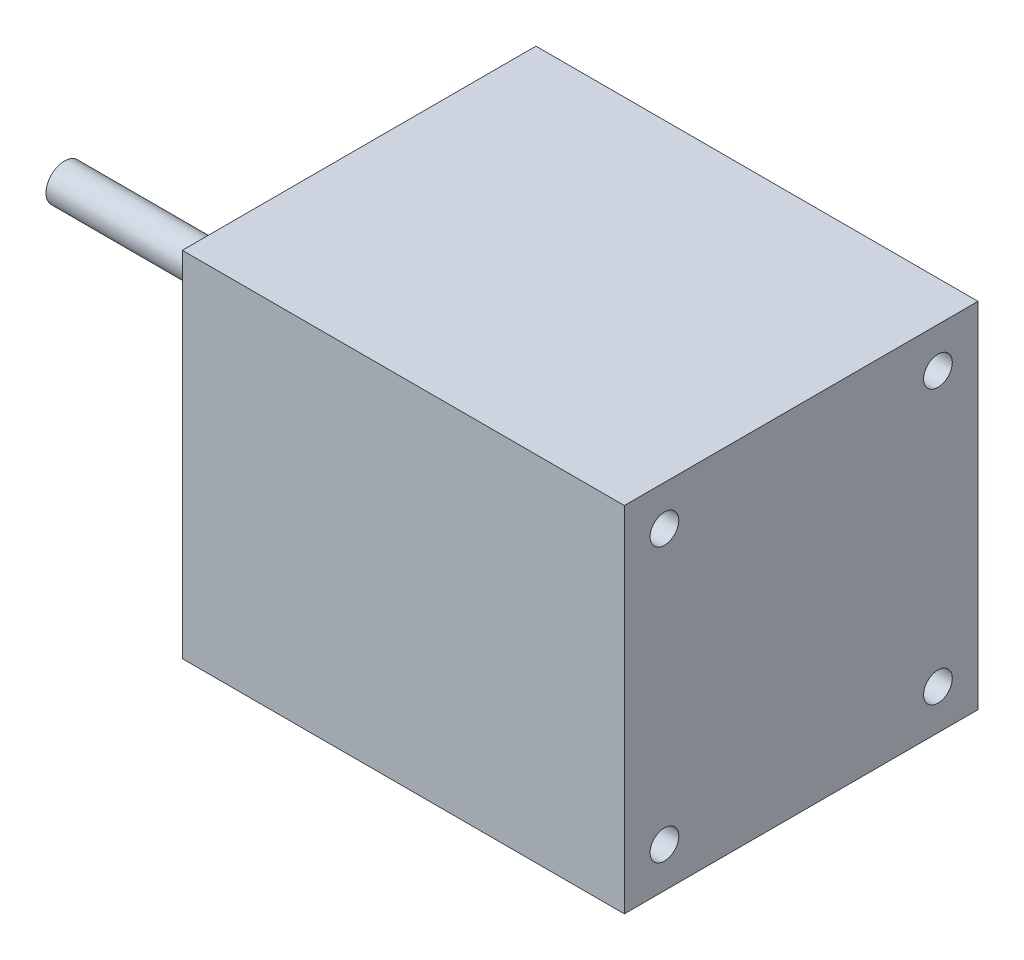
from build123d import *

# Parameters (mm, degrees)
SKETCH1_W           = 60.96
SKETCH1_H           = 60.96
SKETCH1_R           = 2.4765
BOSS_EXTRUDE3_DEPTH = 76.2
SKETCH3_R           = 3.175
BOSS_EXTRUDE4_DEPTH = 50.8


with BuildPart() as part:
    # Sketch1 → Boss-Extrude3 (new body)
    with BuildSketch(Plane(origin=(0, 0, 0), x_dir=(0, 0, -1), z_dir=(1, 0, 0))):
        Rectangle(SKETCH1_W, SKETCH1_H)
        with Locations((-23.573172318, 23.573172318)):
            Circle(SKETCH1_R, mode=Mode.SUBTRACT)
        with Locations((23.573172318, 23.573172318)):
            Circle(SKETCH1_R, mode=Mode.SUBTRACT)
        with Locations((23.573172318, -23.573172318)):
            Circle(SKETCH1_R, mode=Mode.SUBTRACT)
        with Locations((-23.573172318, -23.573172318)):
            Circle(SKETCH1_R, mode=Mode.SUBTRACT)
    extrude(amount=BOSS_EXTRUDE3_DEPTH)

    # Sketch3 → Boss-Extrude4 (add)
    with BuildSketch(Plane.ZY):
        Circle(SKETCH3_R)
    extrude(amount=BOSS_EXTRUDE4_DEPTH)


solid = part.part
